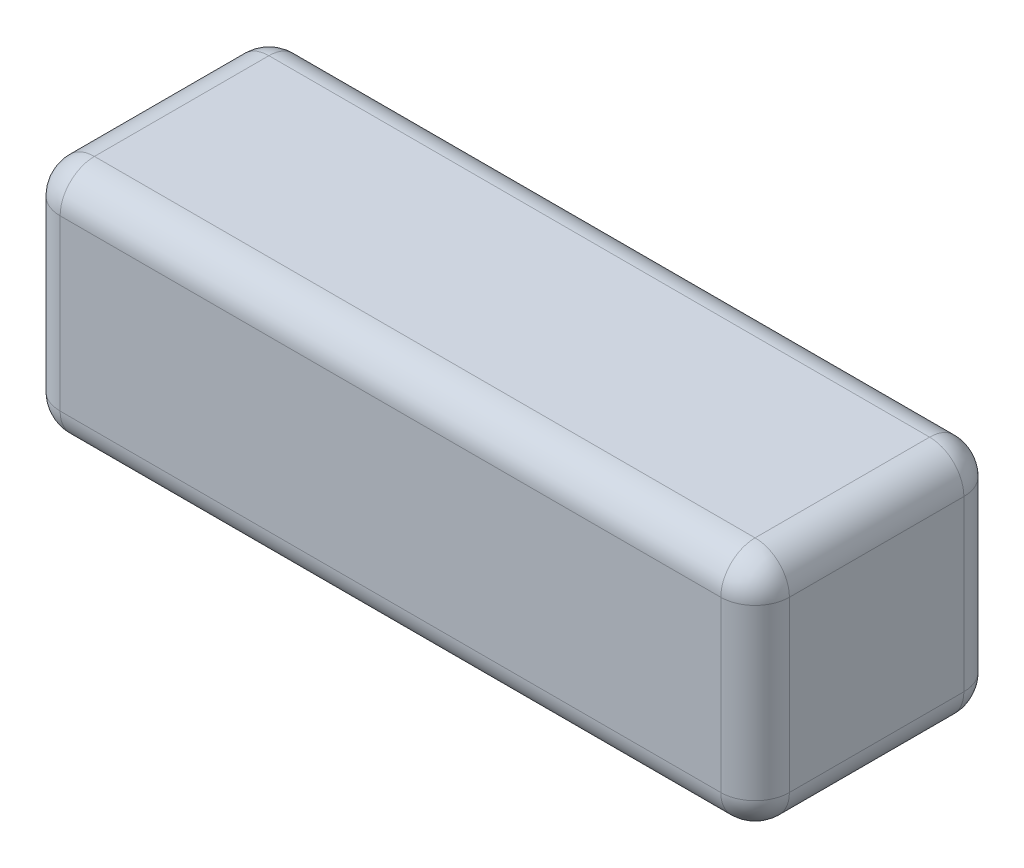
from build123d import *

# Parameters (mm, degrees)
SKETCH1_W           = 135
SKETCH1_H           = 45
BOSS_EXTRUDE1_DEPTH = 44
FILLET1_R           = 6.35


with BuildPart() as part:
    # Sketch1 → Boss-Extrude1 (new body)
    with BuildSketch(Plane(origin=(0, 0, 0), x_dir=(1, 0, 0), z_dir=(0, 1, 0))):
        with Locations((67.5, -22.5)):
            Rectangle(SKETCH1_W, SKETCH1_H)
    extrude(amount=BOSS_EXTRUDE1_DEPTH)

    # Fillet1
    fillet1_edges = [part.edges().sort_by_distance(p)[0] for p in [
        (135, 44, 22.5),
        (67.5, 44, 0),
        (0, 44, 22.5),
        (67.5, 0, 0),
        (135, 0, 22.5),
        (67.5, 0, 45),
        (0, 0, 22.5),
        (0, 22, 0),
        (135, 22, 0),
        (135, 22, 45),
        (0, 22, 45),
        (67.5, 44, 45),
    ]]
    fillet(fillet1_edges, radius=FILLET1_R)


solid = part.part
